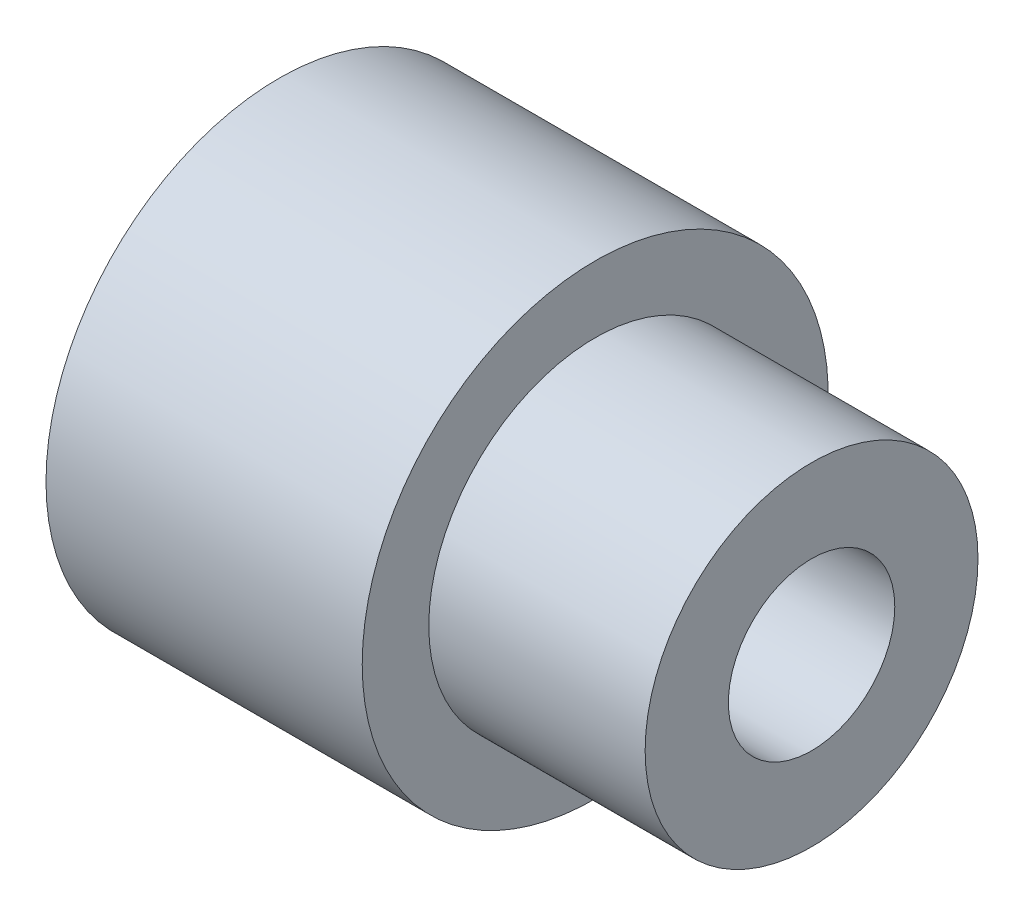
from build123d import *

# Parameters (mm, degrees)
SKETCH1_R           = 10
BOSS_EXTRUDE1_DEPTH = 13
SKETCH2_R           = 14
BOSS_EXTRUDE2_DEPTH = 19
SKETCH3_R           = 11
CUT_EXTRUDE1_DEPTH  = 6
SKETCH4_R           = 9
CUT_EXTRUDE2_DEPTH  = 10
SKETCH5_R           = 5
CUT_EXTRUDE3_DEPTH  = 33
FILLET1_R           = 0.05


with BuildPart() as part:
    # Sketch1 → Boss-Extrude1 (new body)
    with BuildSketch(Plane(origin=(0, 0, 0), x_dir=(0, 0, -1), z_dir=(1, 0, 0))):
        Circle(SKETCH1_R)
    extrude(amount=BOSS_EXTRUDE1_DEPTH)

    # Sketch2 → Boss-Extrude2 (add)
    with BuildSketch(Plane.ZY):
        Circle(SKETCH2_R)
    extrude(amount=BOSS_EXTRUDE2_DEPTH)

    # Sketch3 → Cut-Extrude1 (cut)
    with BuildSketch(Plane.ZY.offset(19)):
        Circle(SKETCH3_R)
    extrude(amount=-CUT_EXTRUDE1_DEPTH, mode=Mode.SUBTRACT)

    # Sketch4 → Cut-Extrude2 (cut)
    with BuildSketch(Plane.ZY.offset(13)):
        Circle(SKETCH4_R)
    extrude(amount=-CUT_EXTRUDE2_DEPTH, mode=Mode.SUBTRACT)

    # Sketch5 → Cut-Extrude3 (cut, through all)
    with BuildSketch(Plane(origin=(13, 0, 0), x_dir=(0, 0, -1), z_dir=(1, 0, 0))):
        Circle(SKETCH5_R)
    extrude(amount=-CUT_EXTRUDE3_DEPTH, mode=Mode.SUBTRACT)

    # Fillet1
    fillet1_edges = [part.edges().sort_by_distance(p)[0] for p in [
        (-19, 0, -11),
    ]]
    fillet(fillet1_edges, radius=FILLET1_R)


solid = part.part
